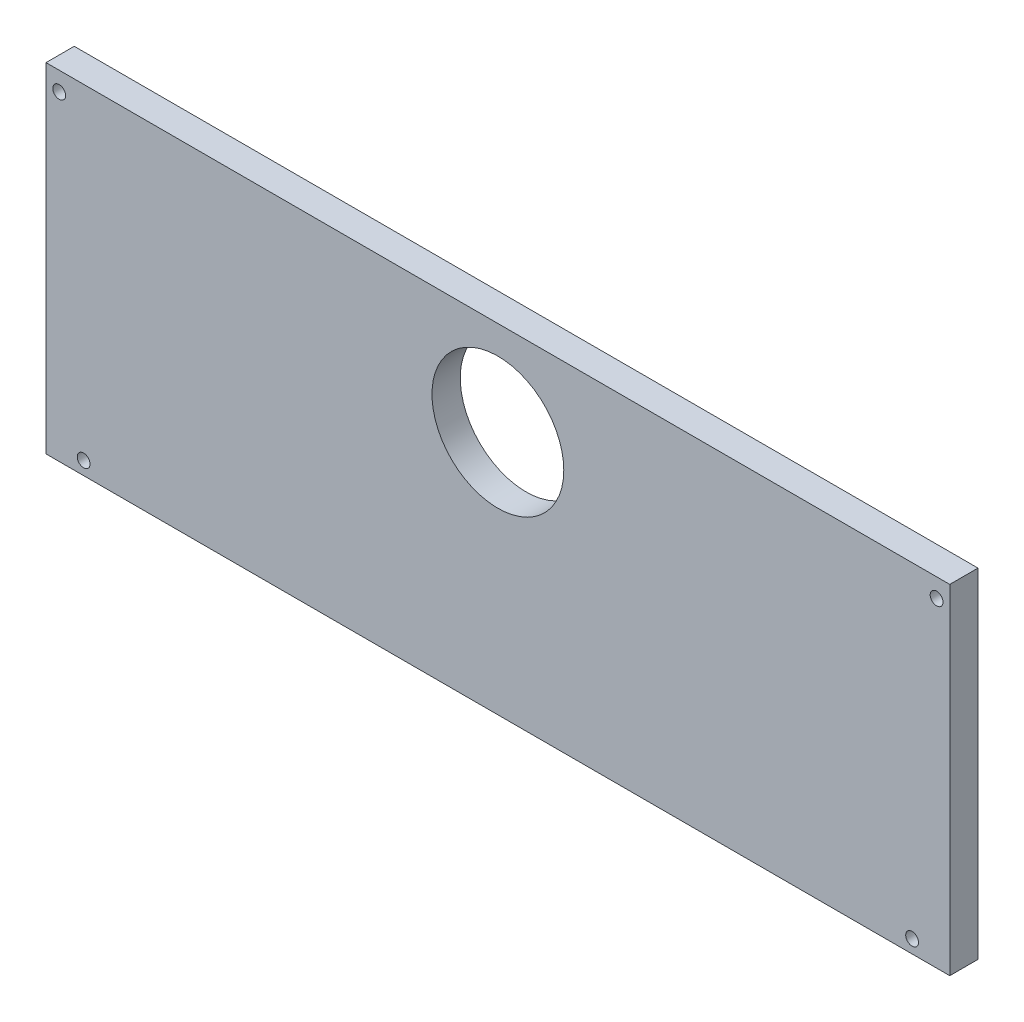
from build123d import *

# Parameters (mm, degrees)
SKETCH1_W           = 304.8
SKETCH1_H           = 114.3
SKETCH1_R           = 22.225
BOSS_EXTRUDE1_DEPTH = 9.525
SKETCH2_R           = 2.159
CUT_EXTRUDE1_DEPTH  = 10.525


with BuildPart() as part:
    # Sketch1 → Boss-Extrude1 (new body)
    with BuildSketch(Plane.XY):
        with Locations((0, -25.4)):
            Rectangle(SKETCH1_W, SKETCH1_H)
        Circle(SKETCH1_R, mode=Mode.SUBTRACT)
    extrude(amount=BOSS_EXTRUDE1_DEPTH)

    # Sketch2 → Cut-Extrude1 (cut, through all)
    with BuildSketch(Plane.XY.offset(9.525)):
        with Locations((-139.7, -78.105)):
            Circle(SKETCH2_R)
        with Locations((-147.955, 25.4)):
            Circle(SKETCH2_R)
        with Locations((147.955, 25.4)):
            Circle(SKETCH2_R)
        with Locations((139.7, -78.105)):
            Circle(SKETCH2_R)
    extrude(amount=-CUT_EXTRUDE1_DEPTH, mode=Mode.SUBTRACT)


solid = part.part
